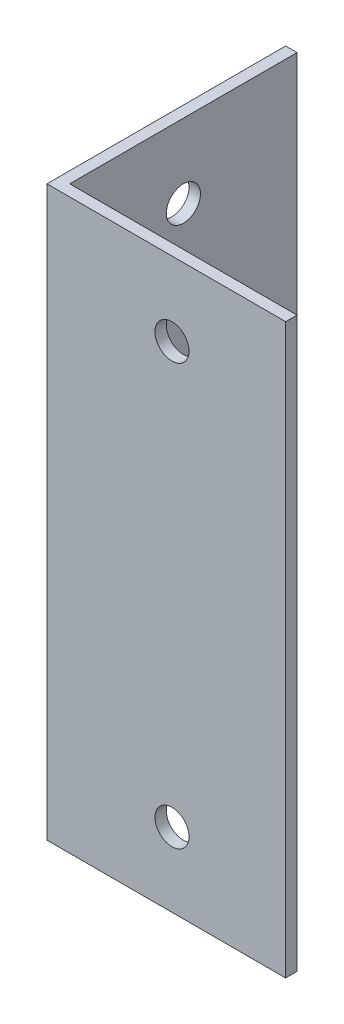
from build123d import *

# Parameters (mm, degrees)
EXTRUSION1_DEPTH = 50
EXTRUSION2_REACH = 3
ESQUISSE2_R      = 1.5
EXTRUSION3_REACH = 3
ESQUISSE3_R      = 1.5


with BuildPart() as part:
    # Esquisse1 → Extrusion1 (new body)
    with BuildSketch(Plane(origin=(0, 0, 0), x_dir=(1, 0, 0), z_dir=(0, 1, 0))):
        Polygon((0, 0), (0, 21), (1, 21), (1, 1), (21, 1), (21, 0), align=None)
    extrude(amount=EXTRUSION1_DEPTH)

    # Esquisse2 → Extrusion2 (cut, up to next)
    with BuildSketch(Plane(origin=(1, 0, 0), x_dir=(0, 0, -1), z_dir=(1, 0, 0)), mode=Mode.PRIVATE) as extrusion2_sk1:
        with Locations((11, 6.5)):
            Circle(ESQUISSE2_R)
    extrusion2_tool1 = extrude(extrusion2_sk1.sketch, amount=-EXTRUSION2_REACH, mode=Mode.PRIVATE) & part.part
    add(extrusion2_tool1.solids().sort_by_distance((1, 6.5, -11))[0], mode=Mode.SUBTRACT)
    # Esquisse2 → Extrusion2 (cut, up to next)
    with BuildSketch(Plane(origin=(1, 0, 0), x_dir=(0, 0, -1), z_dir=(1, 0, 0)), mode=Mode.PRIVATE) as extrusion2_sk2:
        with Locations((11, 43.5)):
            Circle(ESQUISSE2_R)
    extrusion2_tool2 = extrude(extrusion2_sk2.sketch, amount=-EXTRUSION2_REACH, mode=Mode.PRIVATE) & part.part
    add(extrusion2_tool2.solids().sort_by_distance((1, 43.5, -11))[0], mode=Mode.SUBTRACT)

    # Esquisse3 → Extrusion3 (cut, up to next)
    with BuildSketch(Plane(origin=(0, 0, -1), x_dir=(-1, 0, 0), z_dir=(0, 0, -1)), mode=Mode.PRIVATE) as extrusion3_sk1:
        with Locations((-11, 43.5)):
            Circle(ESQUISSE3_R)
    extrusion3_tool1 = extrude(extrusion3_sk1.sketch, amount=-EXTRUSION3_REACH, mode=Mode.PRIVATE) & part.part
    add(extrusion3_tool1.solids().sort_by_distance((11, 43.5, -1))[0], mode=Mode.SUBTRACT)
    # Esquisse3 → Extrusion3 (cut, up to next)
    with BuildSketch(Plane(origin=(0, 0, -1), x_dir=(-1, 0, 0), z_dir=(0, 0, -1)), mode=Mode.PRIVATE) as extrusion3_sk2:
        with Locations((-11, 6.5)):
            Circle(ESQUISSE3_R)
    extrusion3_tool2 = extrude(extrusion3_sk2.sketch, amount=-EXTRUSION3_REACH, mode=Mode.PRIVATE) & part.part
    add(extrusion3_tool2.solids().sort_by_distance((11, 6.5, -1))[0], mode=Mode.SUBTRACT)


solid = part.part
